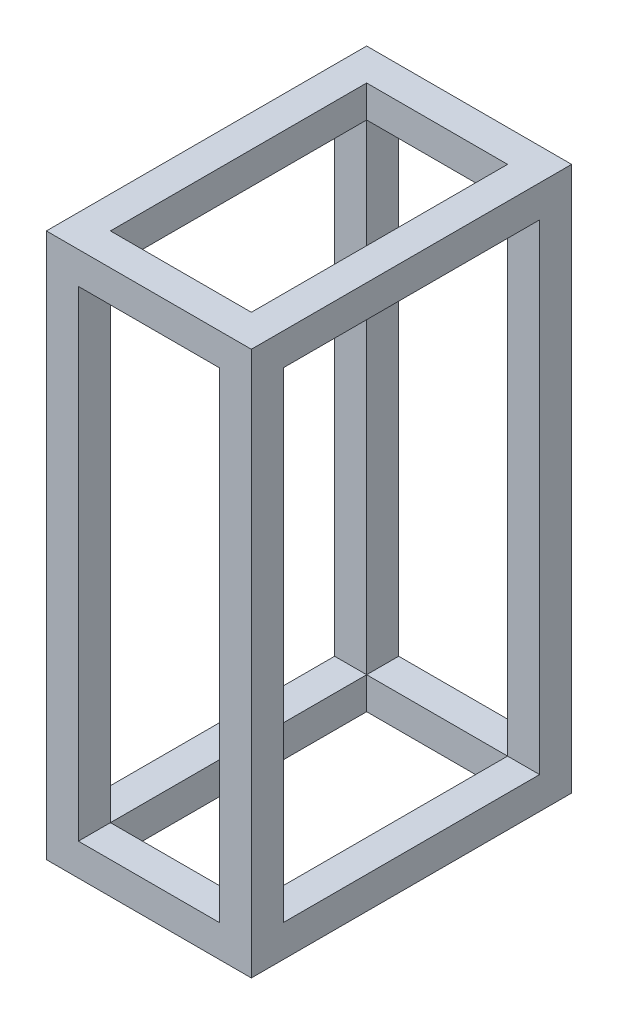
from build123d import *

# Parameters (mm, degrees)
SKETCH1_W           = 16
SKETCH1_H           = 25
SKETCH1_W_2         = 11
SKETCH1_H_2         = 20
BOSS_EXTRUDE2_DEPTH = 2.5
SKETCH1_4_W         = 2.5
SKETCH1_4_H         = 2.5
BOSS_EXTRUDE3_DEPTH = 40
BOSS_EXTRUDE4_START = 40
SKETCH1_5_W         = 2.5
SKETCH1_5_H         = 20
SKETCH1_5_H_2       = 2.5
SKETCH1_5_W_2       = 11
BOSS_EXTRUDE4_DEPTH = 2.5


with BuildPart() as part:
    # Sketch1 → Boss-Extrude2 (new body)
    with BuildSketch(Plane(origin=(0, 0, 0), x_dir=(1, 0, 0), z_dir=(0, 1, 0))):
        with Locations((-8, 12.5)):
            Rectangle(SKETCH1_W, SKETCH1_H)
        with Locations((-8, 12.5)):
            Rectangle(SKETCH1_W_2, SKETCH1_H_2, mode=Mode.SUBTRACT)
    extrude(amount=BOSS_EXTRUDE2_DEPTH)

    # Sketch1_4 → Boss-Extrude3 (add)
    with BuildSketch(Plane(origin=(0, 0, 0), x_dir=(1, 0, 0), z_dir=(0, 1, 0))):
        with Locations((-14.75, 23.75)):
            Rectangle(SKETCH1_4_W, SKETCH1_4_H)
        with Locations((-14.75, 1.25)):
            Rectangle(SKETCH1_4_W, SKETCH1_4_H)
        with Locations((-1.25, 1.25)):
            Rectangle(SKETCH1_4_W, SKETCH1_4_H)
        with Locations((-1.25, 23.75)):
            Rectangle(SKETCH1_4_W, SKETCH1_4_H)
    extrude(amount=BOSS_EXTRUDE3_DEPTH)

    # Sketch1_5 → Boss-Extrude4 (add)
    with BuildSketch(Plane(origin=(0, 0, 0), x_dir=(1, 0, 0), z_dir=(0, 1, 0)).offset(BOSS_EXTRUDE4_START)):
        with Locations((-1.25, 12.5)):
            Rectangle(SKETCH1_5_W, SKETCH1_5_H)
        with Locations((-1.25, 1.25)):
            Rectangle(SKETCH1_5_W, SKETCH1_5_H_2)
        with Locations((-8, 1.25)):
            Rectangle(SKETCH1_5_W_2, SKETCH1_5_H_2)
        with Locations((-14.75, 1.25)):
            Rectangle(SKETCH1_5_W, SKETCH1_5_H_2)
        with Locations((-14.75, 12.5)):
            Rectangle(SKETCH1_5_W, SKETCH1_5_H)
        with Locations((-14.75, 23.75)):
            Rectangle(SKETCH1_5_W, SKETCH1_5_H_2)
        with Locations((-8, 23.75)):
            Rectangle(SKETCH1_5_W_2, SKETCH1_5_H_2)
        with Locations((-1.25, 23.75)):
            Rectangle(SKETCH1_5_W, SKETCH1_5_H_2)
    extrude(amount=BOSS_EXTRUDE4_DEPTH)


solid = part.part
